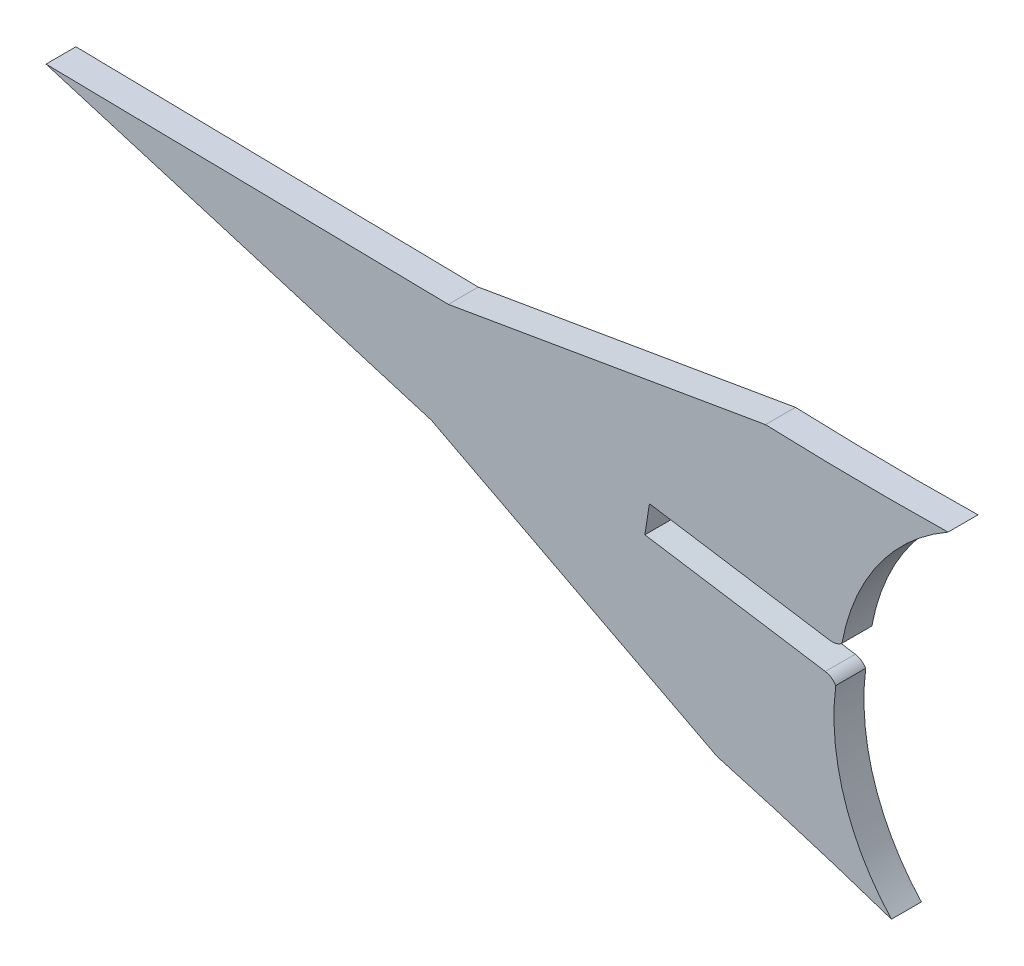
from build123d import *

# Parameters (mm, degrees)
BOSS_EXTRUDE1_DEPTH = 1.524


with BuildPart() as part:
    # Sketch1 → Boss-Extrude1 (new body)
    with BuildSketch(Plane.XY):
        with BuildLine():
            Line((243.009394749, 226.483628693), (252.19647472, 225.051376489))
            ThreePointArc((252.19647472, 225.051376489), (252.501172451, 224.932897548), (252.728179767, 224.697640997))
            ThreePointArc((252.728179767, 224.697640997), (253.158948075, 219.940008266), (255.562248507, 215.811476133))
            ThreePointArc((255.562248507, 215.811476133), (251.141222731, 217.242232573), (246.682055702, 218.549275922))
            Line((246.682055702, 218.549275922), (232.141476548, 226.101345829))
            Line((232.141476548, 226.101345829), (212.521244057, 231.994935761))
            Line((212.521244057, 231.994935761), (233.004487141, 231.64183795))
            Line((233.004487141, 231.64183795), (249.153153432, 234.413620597))
            ThreePointArc((249.153153432, 234.413620597), (253.798600989, 234.302490495), (258.445341479, 234.320813134))
            ThreePointArc((258.445341479, 234.320813134), (254.900209484, 231.11883411), (253.042819444, 226.717614645))
            ThreePointArc((253.042819444, 226.717614645), (252.755013662, 226.562547569), (252.428715894, 226.542355168))
            Line((252.428715894, 226.542355168), (243.241260726, 227.972198625))
            Line((243.241260726, 227.972198625), (243.009394749, 226.483628693))
        make_face()
    extrude(amount=BOSS_EXTRUDE1_DEPTH)


solid = part.part
